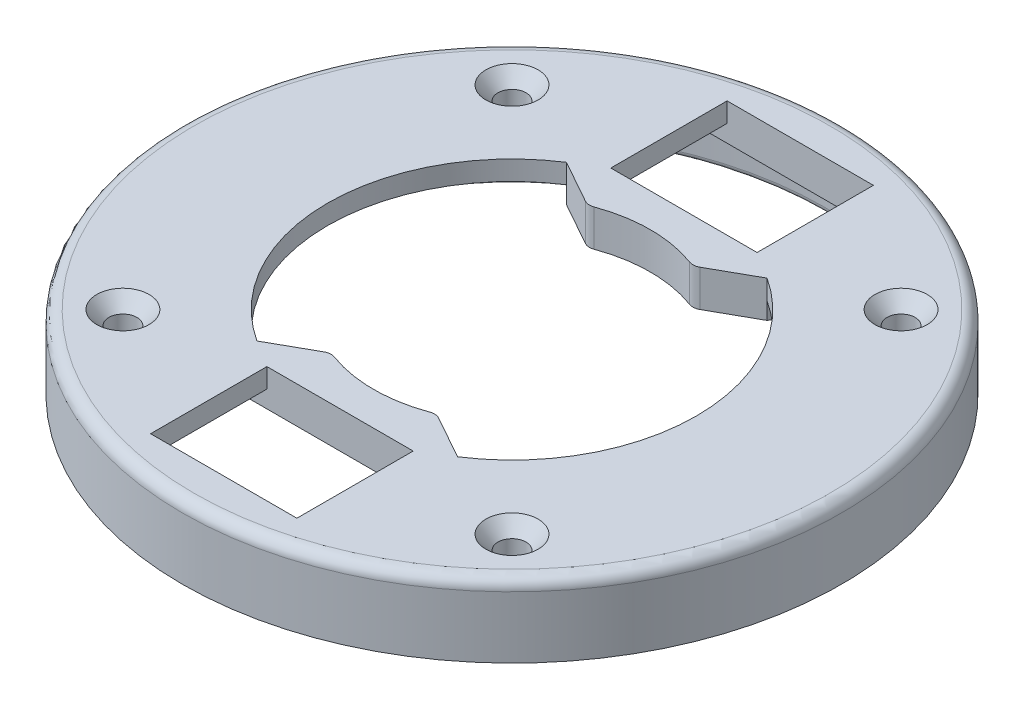
from build123d import *

# Parameters (mm, degrees)
SKETCH1_R                                         = 57.5
BOSS_EXTRUDE1_DEPTH                               = 6.4
SKETCH2_W                                         = 25.525
SKETCH2_H                                         = 20.295
CUT_EXTRUDE1_DEPTH                                = 7.4
SKETCH3_W                                         = 4
SKETCH3_H                                         = 20.295
CUT_EXTRUDE2_DEPTH                                = 3
CUT_EXTRUDE3_DEPTH                                = 3
SKETCH5_R                                         = 1
CUT_EXTRUDE4_DEPTH                                = 7.4
CSK_FOR_8_FLAT_HEAD_SOCKET_CAP_SCREW1_D           = 4.9149
CSK_FOR_8_FLAT_HEAD_SOCKET_CAP_SCREW1_CSINK_D     = 9.1186
CSK_FOR_8_FLAT_HEAD_SOCKET_CAP_SCREW1_CSINK_ANGLE = 82
BOSS_EXTRUDE2_DEPTH                               = 6.4
FILLET1_R                                         = 2
SKETCH10_R                                        = 57.5
SKETCH10_R_2                                      = 54.5
BOSS_EXTRUDE3_DEPTH                               = 6.375
FILLET2_R                                         = 1


with BuildPart() as part:
    # Sketch1 → Boss-Extrude1 (new body)
    with BuildSketch(Plane(origin=(0, 0, 0), x_dir=(1, 0, 0), z_dir=(0, 1, 0))):
        Circle(SKETCH1_R)
        with BuildLine():
            Line((-17.49944642, 27), (17.49944642, 27))
            ThreePointArc((17.49944642, 27), (32.175, 0), (17.49944642, -27))
            Line((17.49944642, -27), (-17.49944642, -27))
            ThreePointArc((-17.49944642, -27), (-32.175, 0), (-17.49944642, 27))
        make_face(mode=Mode.SUBTRACT)
    extrude(amount=BOSS_EXTRUDE1_DEPTH)

    # Sketch2 → Cut-Extrude1 (cut, through all)
    with BuildSketch(Plane(origin=(0, 6.4, 0), x_dir=(1, 0, 0), z_dir=(0, 1, 0))):
        with Locations((0, 40.1475)):
            Rectangle(SKETCH2_W, SKETCH2_H)
        with Locations((0, -40.1475)):
            Rectangle(SKETCH2_W, SKETCH2_H)
    extrude(amount=-CUT_EXTRUDE1_DEPTH, mode=Mode.SUBTRACT)

    # Sketch3 → Cut-Extrude2 (cut)
    with BuildSketch(Plane.XZ):
        with Locations((14.7625, 40.1475)):
            Rectangle(SKETCH3_W, SKETCH3_H)
        with Locations((-14.7625, 40.1475)):
            Rectangle(SKETCH3_W, SKETCH3_H)
        with Locations((14.7625, -40.1475)):
            Rectangle(SKETCH3_W, SKETCH3_H)
        with Locations((-14.7625, -40.1475)):
            Rectangle(SKETCH3_W, SKETCH3_H)
    extrude(amount=-CUT_EXTRUDE2_DEPTH, mode=Mode.SUBTRACT)

    # Sketch4 → Cut-Extrude3 (cut)
    with BuildSketch(Plane.XZ):
        with BuildLine():
            Line((-19.770159359, 30.503496503), (-17.49944642, 27))
            ThreePointArc((-17.49944642, 27), (-32.175, 0), (-17.49944642, -27))
            Line((-17.49944642, -27), (-19.770159359, -30.503496503))
            ThreePointArc((-19.770159359, -30.503496503), (-36.35, 0), (-19.770159359, 30.503496503))
        make_face()
        with BuildLine():
            ThreePointArc((19.770159359, 30.503496503), (36.35, 0), (19.770159359, -30.503496503))
            Line((19.770159359, -30.503496503), (17.49944642, -27))
            ThreePointArc((17.49944642, -27), (32.175, 0), (17.49944642, 27))
            Line((17.49944642, 27), (19.770159359, 30.503496503))
        make_face()
    extrude(amount=-CUT_EXTRUDE3_DEPTH, mode=Mode.SUBTRACT)

    # Sketch5 → Cut-Extrude4 (cut, through all)
    with BuildSketch(Plane.XZ):
        with Locations((-33.941125497, 33.941125497)):
            Circle(SKETCH5_R)
        with Locations((33.941125497, 33.941125497)):
            Circle(SKETCH5_R)
        with Locations((33.941125497, -33.941125497)):
            Circle(SKETCH5_R)
        with Locations((-33.941125497, -33.941125497)):
            Circle(SKETCH5_R)
    extrude(amount=-CUT_EXTRUDE4_DEPTH, mode=Mode.SUBTRACT)

    # CSK for #8 Flat Head Socket Cap Screw1 (through all)
    with Locations(Plane(origin=(0, 6.4, 0), x_dir=(1, 0, 0), z_dir=(0, 1, 0))):
        with Locations((-33.941125497, 33.941125497), (33.941125497, 33.941125497), (33.941125497, -33.941125497), (-33.941125497, -33.941125497)):
            CounterSinkHole(CSK_FOR_8_FLAT_HEAD_SOCKET_CAP_SCREW1_D / 2, CSK_FOR_8_FLAT_HEAD_SOCKET_CAP_SCREW1_CSINK_D / 2, counter_sink_angle=CSK_FOR_8_FLAT_HEAD_SOCKET_CAP_SCREW1_CSINK_ANGLE)

    # Sketch9 → Boss-Extrude2 (add)
    with BuildSketch(Plane(origin=(0, 6.4, 0), x_dir=(1, 0, 0), z_dir=(0, 1, 0))):
        with BuildLine():
            Line((-17.49944642, 27), (17.49944642, 27))
            Line((17.49944642, 27), (9.178880504, 22.337651011))
            ThreePointArc((9.178880504, 22.337651011), (0, 24.15), (-9.178880504, 22.337651011))
            Line((-9.178880504, 22.337651011), (-17.49944642, 27))
        make_face()
        with BuildLine():
            Line((17.49944642, -27), (9.178880504, -22.337651011))
            ThreePointArc((9.178880504, -22.337651011), (0, -24.15), (-9.178880504, -22.337651011))
            Line((-9.178880504, -22.337651011), (-17.49944642, -27))
            Line((-17.49944642, -27), (17.49944642, -27))
        make_face()
    extrude(amount=-BOSS_EXTRUDE2_DEPTH)

    # Fillet1
    fillet1_edges = [part.edges().sort_by_distance(p)[0] for p in [
        (9.178880504, 3.2, -22.337651011),
        (-9.178880504, 3.2, -22.337651011),
        (-9.178880504, 3.2, 22.337651011),
        (9.178880504, 3.2, 22.337651011),
        (-57.5, 6.4, 0),
    ]]
    fillet(fillet1_edges, radius=FILLET1_R)

    # Sketch10 → Boss-Extrude3 (add)
    with BuildSketch(Plane.XZ):
        Circle(SKETCH10_R)
        Circle(SKETCH10_R_2, mode=Mode.SUBTRACT)
    extrude(amount=BOSS_EXTRUDE3_DEPTH)

    # Fillet2
    fillet2_edges = [part.edges().sort_by_distance(p)[0] for p in [
        (-54.5, -6.375, 0),
    ]]
    fillet(fillet2_edges, radius=FILLET2_R)


solid = part.part
